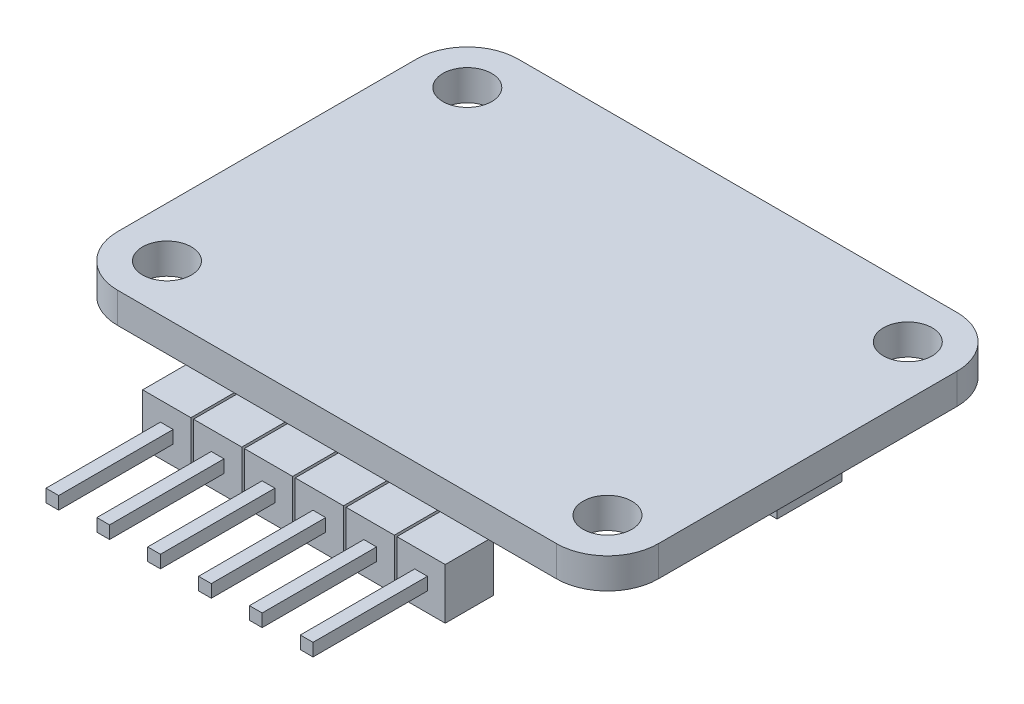
from build123d import *

# Parameters (mm, degrees)
SKETCH1_W           = 27
SKETCH1_H           = 20
SKETCH1_R           = 1.2192
BOSS_EXTRUDE1_DEPTH = 1.524
SKETCH3_W           = 2.413
SKETCH3_H           = 2.413
BOSS_EXTRUDE2_DEPTH = 2.54
SKETCH4_W           = 0.635
SKETCH4_H           = 0.635
BOSS_EXTRUDE3_DEPTH = 5.715
FILLET1_R           = 2.54
SKETCH5_W           = 7.7851
SKETCH5_H           = 3.2512
SKETCH5_R           = 0.381
BOSS_EXTRUDE4_DEPTH = 2.1971


with BuildPart() as part:
    # Sketch1 → Boss-Extrude1 (new body)
    with BuildSketch(Plane(origin=(0, 0, 0), x_dir=(1, 0, 0), z_dir=(0, 1, 0))):
        with Locations((13.5, 10)):
            Rectangle(SKETCH1_W, SKETCH1_H)
        with Locations((2.5, 17.5)):
            Circle(SKETCH1_R, mode=Mode.SUBTRACT)
        with Locations((24.5, 17.5)):
            Circle(SKETCH1_R, mode=Mode.SUBTRACT)
        with Locations((24.5, 2.5)):
            Circle(SKETCH1_R, mode=Mode.SUBTRACT)
        with Locations((2.5, 2.5)):
            Circle(SKETCH1_R, mode=Mode.SUBTRACT)
    extrude(amount=BOSS_EXTRUDE1_DEPTH)

    # Sketch3 → Boss-Extrude2 (add)
    with BuildSketch(Plane(origin=(0, 0, 0), x_dir=(-1, 0, 0), z_dir=(0, -1, 0))):
        with Locations((-19.85, -0.9525)):
            Rectangle(SKETCH3_W, SKETCH3_H)
        with Locations((-14.77, -0.9525)):
            Rectangle(SKETCH3_W, SKETCH3_H)
        with Locations((-12.23, -0.9525)):
            Rectangle(SKETCH3_W, SKETCH3_H)
        with Locations((-9.69, -0.9525)):
            Rectangle(SKETCH3_W, SKETCH3_H)
        with Locations((-7.15, -0.9525)):
            Rectangle(SKETCH3_W, SKETCH3_H)
        with Locations((-17.31, -0.9525)):
            Rectangle(SKETCH3_W, SKETCH3_H)
    extrude(amount=BOSS_EXTRUDE2_DEPTH)

    # Sketch4 → Boss-Extrude3 (add)
    with BuildSketch(Plane.XY.offset(2.159)):
        with Locations((17.31, -1.27)):
            Rectangle(SKETCH4_W, SKETCH4_H)
        with Locations((7.15, -1.27)):
            Rectangle(SKETCH4_W, SKETCH4_H)
        with Locations((9.69, -1.27)):
            Rectangle(SKETCH4_W, SKETCH4_H)
        with Locations((12.23, -1.27)):
            Rectangle(SKETCH4_W, SKETCH4_H)
        with Locations((14.77, -1.27)):
            Rectangle(SKETCH4_W, SKETCH4_H)
        with Locations((19.85, -1.27)):
            Rectangle(SKETCH4_W, SKETCH4_H)
    extrude(amount=BOSS_EXTRUDE3_DEPTH)

    # Fillet1
    fillet1_edges = [part.edges().sort_by_distance(p)[0] for p in [
        (0, 0.762, -20),
        (27, 0.762, -20),
        (27, 0.762, 0),
        (0, 0.762, 0),
    ]]
    fillet(fillet1_edges, radius=FILLET1_R)

    # Sketch5 → Boss-Extrude4 (add)
    with BuildSketch(Plane.XZ):
        with Locations((21.287352133, -11.916943925)):
            Rectangle(SKETCH5_W, SKETCH5_H)
        with Locations((23.50781589, -11.916943925)):
            Circle(SKETCH5_R, mode=Mode.SUBTRACT)
    extrude(amount=BOSS_EXTRUDE4_DEPTH)


solid = part.part
